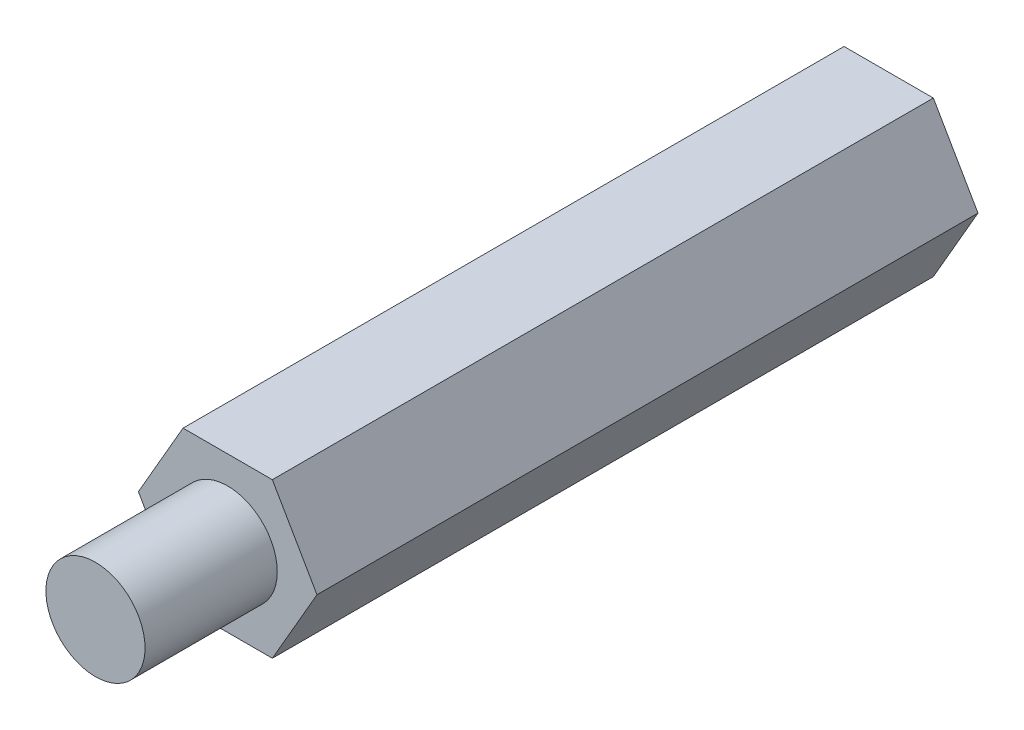
from build123d import *

# Parameters (mm, degrees)
EXTRUDE_1_DEPTH = 20
SKETCH_2_R      = 1.5
EXTRUDE_2_DEPTH = 4
M3X0_5_1_D      = 2.5
M3X0_5_1_DEPTH  = 5
M3X0_5_1_TIP    = 0.751075774


with BuildPart() as part:
    # 草圖1 → 填料-伸長1 (new body)
    with BuildSketch(Plane.XY):
        Polygon((2.70199926, 0), (1.35099963, 2.34), (-1.35099963, 2.34), (-2.70199926, 0), (-1.35099963, -2.34), (1.35099963, -2.34), align=None)
    extrude(amount=EXTRUDE_1_DEPTH)

    # 草圖2 → 填料-伸長2 (add)
    with BuildSketch(Plane.XY.offset(20)):
        Circle(SKETCH_2_R)
    extrude(amount=EXTRUDE_2_DEPTH)

    # M3x0.5 螺紋孔1
    with Locations(Plane(origin=(0, 0, 0), x_dir=(-1, 0, 0), z_dir=(0, 0, -1))):
        with Locations((0, 0)):
            Hole(M3X0_5_1_D / 2, depth=M3X0_5_1_DEPTH)
            with Locations((0, 0, -(M3X0_5_1_DEPTH + M3X0_5_1_TIP / 2))):  # 118° drill point
                Cone(0, M3X0_5_1_D / 2, M3X0_5_1_TIP, mode=Mode.SUBTRACT)


solid = part.part
